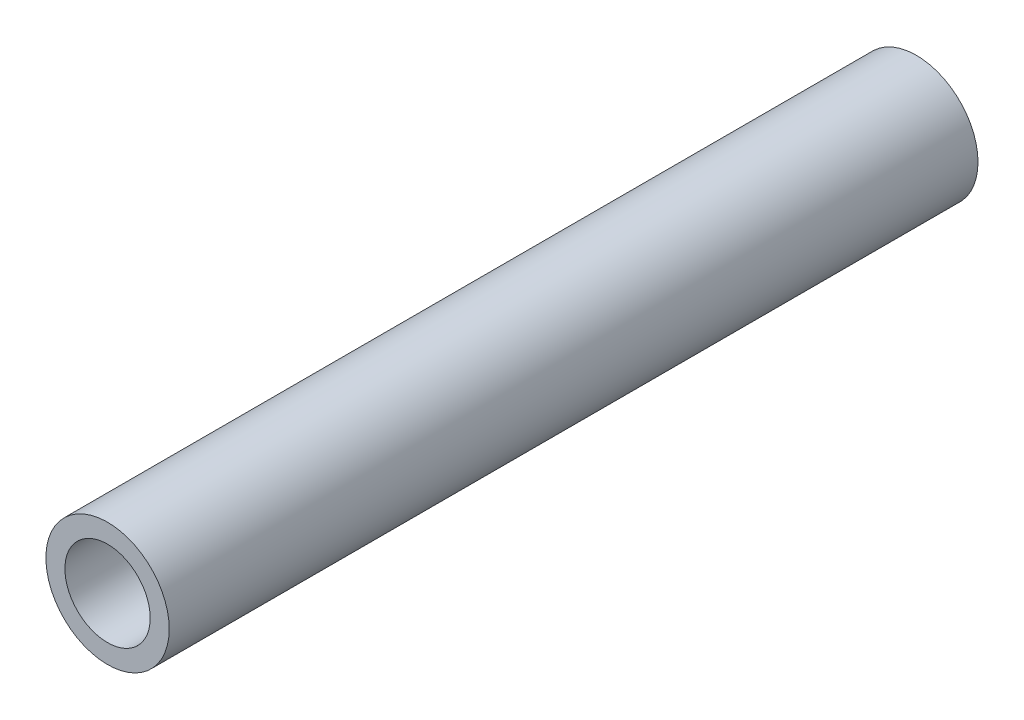
from build123d import *

# Parameters (mm, degrees)
SKETCH1_R           = 7.747
SKETCH1_R_2         = 5.3594
BOSS_EXTRUDE1_DEPTH = 101.6


with BuildPart() as part:
    # Sketch1 → Boss-Extrude1 (new body)
    with BuildSketch(Plane.XY):
        Circle(SKETCH1_R)
        Circle(SKETCH1_R_2, mode=Mode.SUBTRACT)
    extrude(amount=BOSS_EXTRUDE1_DEPTH)


solid = part.part
